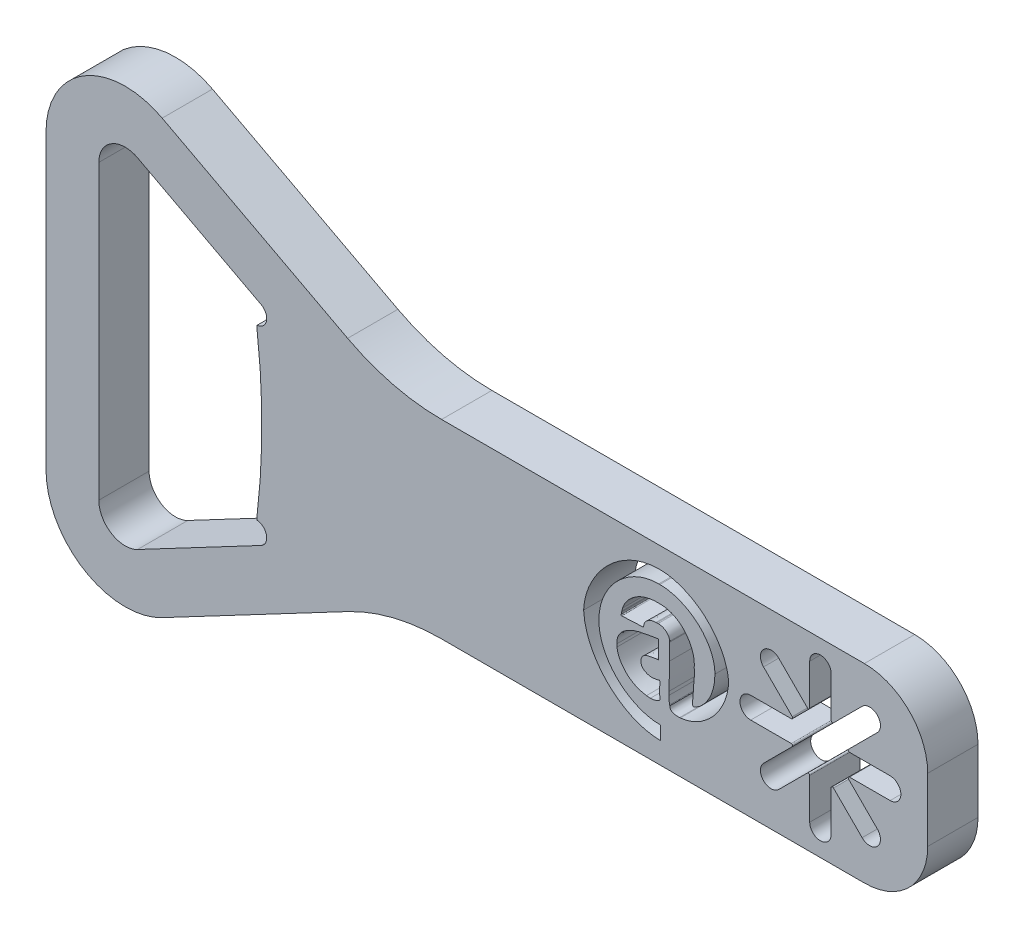
from build123d import *

# Parameters (mm, degrees)
BOSS_EXTRUDE1_DEPTH = 4.7625
CUT_EXTRUDE3_DEPTH  = 5.7625
CUT_EXTRUDE4_DEPTH  = 5.7625
FILLET2_R           = 0.127


with BuildPart() as part:
    # Model → Boss-Extrude1 (new body)
    with BuildSketch(Plane.XY):
        with BuildLine():
            Line((93.450952687, 245.03072761), (75.889188638, 254.308203871))
            ThreePointArc((75.889188638, 254.308203871), (68.514514164, 254.100258783), (64.885909847, 247.676685364))
            Line((64.885909847, 247.676685364), (64.885909847, 219.972883873))
            ThreePointArc((64.885909847, 219.972883873), (68.514514164, 213.549310454), (75.889188638, 213.341365366))
            Line((75.889188638, 213.341365366), (93.450952687, 222.618841627))
            ThreePointArc((93.450952687, 222.618841627), (97.765438869, 224.265076477), (102.349280816, 224.824784618))
            Line((102.349280816, 224.824784618), (142.385909847, 224.824784618))
            ThreePointArc((142.385909847, 224.824784618), (146.628550534, 226.582143931), (148.385909847, 230.824784618))
            Line((148.385909847, 230.824784618), (148.385909847, 236.824784618))
            ThreePointArc((148.385909847, 236.824784618), (146.628550534, 241.067425306), (142.385909847, 242.824784618))
            Line((142.385909847, 242.824784618), (102.349280816, 242.824784618))
            ThreePointArc((102.349280816, 242.824784618), (97.765438869, 243.38449276), (93.450952687, 245.03072761))
        make_face()
        with BuildLine():
            Line((73.553669444, 217.762377704), (85.257358528, 223.945167619))
            ThreePointArc((85.257358528, 223.945167619), (85.71629755, 224.451951724), (85.742353062, 225.135161989))
            ThreePointArc((85.742353062, 225.135161989), (85.41742429, 225.608252807), (84.885909847, 225.824784618))
            Line((84.885909847, 225.824784618), (84.885909847, 226.324784618))
            ThreePointArc((84.885909847, 226.324784618), (85.330378765, 233.824784618), (84.885909847, 241.324784618))
            Line((84.885909847, 241.324784618), (84.885909847, 241.824784618))
            ThreePointArc((84.885909847, 241.824784618), (85.41742429, 242.04131643), (85.742353062, 242.514407247))
            ThreePointArc((85.742353062, 242.514407247), (85.71629755, 243.197617512), (85.257358528, 243.704401618))
            Line((85.257358528, 243.704401618), (73.553669444, 249.887191533))
            ThreePointArc((73.553669444, 249.887191533), (71.095444619, 249.817876503), (69.885909847, 247.676685364))
            Line((69.885909847, 247.676685364), (69.885909847, 219.972883873))
            ThreePointArc((69.885909847, 219.972883873), (71.095444619, 217.831692734), (73.553669444, 217.762377704))
        make_face(mode=Mode.SUBTRACT)
    extrude(amount=BOSS_EXTRUDE1_DEPTH)

    # Sketch4 → Cut-Extrude3 (cut, through all)
    with BuildSketch(Plane.XY.offset(4.7625)):
        with BuildLine():
            Line((137.209909847, 227.223079813), (137.209909847, 231.371943639))
            Line((137.209909847, 231.371943639), (134.276220101, 228.438253894))
            ThreePointArc((134.276220101, 228.438253894), (132.839379122, 228.438253894), (132.839379122, 229.875094873))
            Line((132.839379122, 229.875094873), (135.773068867, 232.808784618))
            Line((135.773068867, 232.808784618), (131.624205042, 232.808784618))
            ThreePointArc((131.624205042, 232.808784618), (130.608205042, 233.824784618), (131.624205042, 234.840784618))
            Line((131.624205042, 234.840784618), (135.773068867, 234.840784618))
            Line((135.773068867, 234.840784618), (132.839379122, 237.774474364))
            ThreePointArc((132.839379122, 237.774474364), (132.839379122, 239.211315343), (134.276220101, 239.211315343))
            Line((134.276220101, 239.211315343), (137.209909847, 236.277625598))
            Line((137.209909847, 236.277625598), (137.209909847, 240.426489423))
            ThreePointArc((137.209909847, 240.426489423), (138.225909847, 241.442489423), (139.241909847, 240.426489423))
            Line((139.241909847, 240.426489423), (139.241909847, 236.277625598))
            Line((139.241909847, 236.277625598), (142.175599592, 239.211315343))
            ThreePointArc((142.175599592, 239.211315343), (143.612440572, 239.211315343), (143.612440572, 237.774474364))
            Line((143.612440572, 237.774474364), (140.678750826, 234.840784618))
            Line((140.678750826, 234.840784618), (144.827614652, 234.840784618))
            ThreePointArc((144.827614652, 234.840784618), (145.843614652, 233.824784618), (144.827614652, 232.808784618))
            Line((144.827614652, 232.808784618), (140.678750826, 232.808784618))
            Line((140.678750826, 232.808784618), (143.612440572, 229.875094873))
            ThreePointArc((143.612440572, 229.875094873), (143.612440572, 228.438253894), (142.175599592, 228.438253894))
            Line((142.175599592, 228.438253894), (139.241909847, 231.371943639))
            Line((139.241909847, 231.371943639), (139.241909847, 227.223079813))
            ThreePointArc((139.241909847, 227.223079813), (138.225909847, 226.207079813), (137.209909847, 227.223079813))
        make_face()
    extrude(amount=-CUT_EXTRUDE3_DEPTH, mode=Mode.SUBTRACT)

    # Sketch5 → Cut-Extrude4 (cut, through all)
    with BuildSketch(Plane.XY.offset(4.7625)):
        with BuildLine():
            add(Edge.make_bspline(
                [(126.288361494, 234.030612945), (126.288361494, 234.062228992), (126.288361494, 234.126390968), (126.288361494, 234.190552945), (126.288361494, 234.223098875)],
                knots=[0, 0, 0, 0, 9.4848e-05, 0.000192486, 0.000192486, 0.000192486, 0.000192486], degree=3))
            add(Edge.make_bspline(
                [(126.288361494, 234.223098875), (126.287357171, 234.260374858), (126.285441418, 234.331478997), (126.274187869, 234.401702957), (126.268833936, 234.435112363)],
                knots=[0, 0, 0, 0, 0.000111725, 0.000213117, 0.000213117, 0.000213117, 0.000213117], degree=3))
            add(Edge.make_bspline(
                [(126.268833936, 234.435112363), (126.269705178, 234.449063035), (126.271683634, 234.480742831), (126.276195212, 234.530214354), (126.28660925, 234.579851384), (126.287813896, 234.61267678), (126.288361494, 234.627598294)],
                knots=[0, 0, 0, 0, 4.1938e-05, 9.5234e-05, 0.000148894, 0.000193615, 0.000193615, 0.000193615, 0.000193615], degree=3))
            add(Edge.make_bspline(
                [(126.288361494, 234.627598294), (126.284874052, 234.739324272), (126.277954936, 234.960989623), (126.230695985, 235.289801797), (126.144832923, 235.609536287), (126.030758138, 235.919931115), (125.89184278, 236.219239832), (125.726670115, 236.500079901), (125.541759748, 236.764765282), (125.334862846, 237.009659426), (125.10970704, 237.237606073), (124.859990194, 237.438308088), (124.591026849, 237.615132637), (124.303890841, 237.764741345), (124.004254122, 237.8891917), (123.692053743, 237.974520596), (123.373339224, 238.030548458), (123.157678136, 238.036405686), (123.049576497, 238.039341662)],
                knots=[0, 0, 0, 0, 0.000335176, 0.000664993, 0.000993841, 0.001326558, 0.001656033, 0.001982338, 0.002302748, 0.002623497, 0.002943055, 0.003262406, 0.003582731, 0.003907159, 0.004232485, 0.004553986, 0.004876393, 0.005200425, 0.005200425, 0.005200425, 0.005200425], degree=3))
            Line((123.049576497, 238.039341662), (122.759452777, 238.039341662))
            Line((122.759452777, 238.039341662), (122.739925218, 238.039341662))
            Line((122.739925218, 238.039341662), (122.700870102, 238.039341662))
            add(Edge.make_bspline(
                [(122.700870102, 238.039341662), (122.532890784, 238.032310589), (122.193481031, 238.018103989), (121.694072094, 237.903577601), (121.209266645, 237.733330729), (120.756781994, 237.492891404), (120.344031914, 237.188375917), (120.042891277, 236.883831305), (119.829268268, 236.614302308), (119.693745608, 236.394972755), (119.573326683, 236.164672688), (119.512463554, 236.001776947), (119.481612663, 235.919206781)],
                knots=[0, 0, 0, 0, 0.000503445, 0.001017233, 0.0015299, 0.002041555, 0.002548167, 0.003063015, 0.003321385, 0.003578351, 0.003835363, 0.004099556, 0.004099556, 0.004099556, 0.004099556], degree=3))
            add(Edge.make_bspline(
                [(119.481612663, 235.919206781), (119.476029997, 235.895032488), (119.465522894, 235.849534197), (119.450389171, 235.783736573), (119.439961658, 235.717000075), (119.428996042, 235.672708367), (119.423029989, 235.648610618)],
                knots=[0, 0, 0, 0, 7.4437e-05, 0.000140098, 0.000202476, 0.000276913, 0.000276913, 0.000276913, 0.000276913], degree=3))
            add(Edge.make_bspline(
                [(119.423029989, 235.648610618), (119.417749333, 235.631067462), (119.408401324, 235.600011927), (119.404987708, 235.567784676), (119.403502431, 235.553762479)],
                knots=[0, 0, 0, 0, 5.4808e-05, 9.7023e-05, 9.7023e-05, 9.7023e-05, 9.7023e-05], degree=3))
            add(Edge.make_bspline(
                [(119.403502431, 235.553762479), (119.399331446, 235.529463416), (119.386890201, 235.456983986), (119.361678872, 235.387763194), (119.344919757, 235.34174899)],
                knots=[0, 0, 0, 0, 7.386e-05, 0.00022031, 0.00022031, 0.00022031, 0.00022031], degree=3))
            add(Edge.make_bspline(
                [(119.344919757, 235.34174899), (119.337968424, 235.328463107), (119.326264529, 235.306093789), (119.326214095, 235.266353615), (119.360790812, 235.243804404), (119.387482155, 235.243996127), (119.403502431, 235.2441112)],
                knots=[0, 0, 0, 0, 4.5068e-05, 7.5881e-05, 0.000107688, 0.000155439, 0.000155439, 0.000155439, 0.000155439], degree=3))
            add(Edge.make_bspline(
                [(119.403502431, 235.2441112), (119.570844616, 235.25586831), (119.904440478, 235.279306054), (120.405794106, 235.303774184), (120.907134076, 235.321959023), (121.241885769, 235.335152335), (121.409261615, 235.34174899)],
                knots=[0, 0, 0, 0, 0.000503252, 0.00100323, 0.001505747, 0.002008264, 0.002008264, 0.002008264, 0.002008264], degree=3))
            add(Edge.make_bspline(
                [(121.409261615, 235.34174899), (121.431913124, 235.342566401), (121.47193382, 235.344010603), (121.482699491, 235.381340603), (121.487371848, 235.397542014)],
                knots=[0, 0, 0, 0, 6.022e-05, 0.000106397, 0.000106397, 0.000106397, 0.000106397], degree=3))
            add(Edge.make_bspline(
                [(121.487371848, 235.397542014), (121.491201998, 235.46513789), (121.498714198, 235.59771593), (121.571888813, 235.783987972), (121.691816601, 235.945189734), (121.850920335, 236.079600892), (122.035966179, 236.183261067), (122.228917359, 236.268810695), (122.433939123, 236.312588896), (122.572378602, 236.319975918), (122.642287428, 236.323706199)],
                knots=[0, 0, 0, 0, 0.000202091, 0.000396368, 0.000589982, 0.000799671, 0.001015936, 0.001224732, 0.001430486, 0.001640378, 0.001640378, 0.001640378, 0.001640378], degree=3))
            Line((122.642287428, 236.323706199), (122.72039766, 236.323706199))
            add(Edge.make_bspline(
                [(122.72039766, 236.323706199), (122.737952884, 236.329039699), (122.781482242, 236.34226447), (122.827087866, 236.342871525), (122.854300916, 236.343233757)],
                knots=[0, 0, 0, 0, 5.4808e-05, 0.0001359, 0.0001359, 0.0001359, 0.0001359], degree=3))
            add(Edge.make_bspline(
                [(122.854300916, 236.343233757), (122.920544034, 236.339687282), (123.052853891, 236.332603775), (123.247737126, 236.285389875), (123.430676504, 236.198059761), (123.601516399, 236.086454092), (123.749124755, 235.949946057), (123.86024378, 235.790137501), (123.923147061, 235.608388815), (123.932112793, 235.481689657), (123.936685566, 235.417069572)],
                knots=[0, 0, 0, 0, 0.000198771, 0.000397013, 0.000596722, 0.000804078, 0.00100734, 0.001196131, 0.001382287, 0.001576062, 0.001576062, 0.001576062, 0.001576062], degree=3))
            Line((123.936685566, 235.417069572), (123.936685566, 235.34174899))
            add(Edge.make_bspline(
                [(123.936685566, 235.34174899), (123.937375637, 235.21342241), (123.938745833, 234.9586187), (123.945025157, 234.578314027), (123.951388449, 234.19801061), (123.952740199, 233.944136484), (123.953423473, 233.815809806)],
                knots=[0, 0, 0, 0, 0.000384982, 0.000764416, 0.00114106, 0.001526042, 0.001526042, 0.001526042, 0.001526042], degree=3))
            add(Edge.make_bspline(
                [(123.953423473, 233.815809806), (123.952176459, 233.603787581), (123.949682178, 233.179700314), (123.934949795, 232.545483984), (123.914327483, 231.915763642), (123.890127163, 231.49849923), (123.878102892, 231.291175506)],
                knots=[0, 0, 0, 0, 0.000636065, 0.001272258, 0.001903114, 0.002526107, 0.002526107, 0.002526107, 0.002526107], degree=3))
            Line((123.878102892, 231.291175506), (123.878102892, 230.961996669))
            add(Edge.make_bspline(
                [(123.878102892, 230.961996669), (123.880605234, 230.841877602), (123.885838923, 230.590646624), (123.919249383, 230.341568757), (123.936685566, 230.211580507)],
                knots=[0, 0, 0, 0, 0.000360135, 0.000753229, 0.000753229, 0.000753229, 0.000753229], degree=3))
            add(Edge.make_bspline(
                [(123.936685566, 230.211580507), (123.936288816, 230.194298861), (123.935619578, 230.165148131), (123.962149175, 230.156513522), (123.972951031, 230.152997833)],
                knots=[0, 0, 0, 0, 4.5412e-05, 7.6601e-05, 7.6601e-05, 7.6601e-05, 7.6601e-05], degree=3))
            add(Edge.make_bspline(
                [(123.972951031, 230.152997833), (123.969677746, 230.115701273), (123.963347915, 230.043577734), (123.993538681, 229.936202659), (124.058453636, 229.843647926), (124.150714237, 229.758963596), (124.282319592, 229.694553439), (124.453269392, 229.655081686), (124.663707985, 229.640900003), (124.816376129, 229.647359743), (124.899115216, 229.650860624)],
                knots=[0, 0, 0, 0, 0.000111621, 0.000215851, 0.000326491, 0.000446964, 0.000587945, 0.000760476, 0.000970368, 0.00121871, 0.00121871, 0.00121871, 0.00121871], degree=3))
            Line((124.899115216, 229.650860624), (124.957697891, 229.650860624))
            add(Edge.make_bspline(
                [(124.957697891, 229.650860624), (125.116423689, 229.672499935), (125.430835481, 229.715364135), (125.890707604, 229.840792108), (126.331759051, 230.017097808), (126.753829843, 230.242168248), (127.154421239, 230.506951649), (127.529346965, 230.806069197), (127.88230805, 231.13039973), (128.20213999, 231.489044016), (128.493855381, 231.8725217), (128.756173255, 232.279139433), (128.98024074, 232.710124345), (129.176625101, 233.157275459), (129.332079182, 233.617400488), (129.444026579, 234.08222801), (129.514124613, 234.547350917), (129.522819173, 234.857972518), (129.527146491, 235.012570154)],
                knots=[0, 0, 0, 0, 0.000480185, 0.000951173, 0.001425685, 0.001902389, 0.002383642, 0.002864191, 0.003339915, 0.003819937, 0.004303675, 0.004784224, 0.005269631, 0.00575938, 0.006248102, 0.006724439, 0.007192336, 0.007655955, 0.007655955, 0.007655955, 0.007655955], degree=3))
            add(Edge.make_bspline(
                [(129.527146491, 235.012570154), (129.499968921, 235.209643523), (129.445645037, 235.603563621), (129.284504493, 236.17831865), (129.07281248, 236.737839285), (128.800748353, 237.274053858), (128.48292554, 237.786371961), (128.125242918, 238.269359083), (127.730841294, 238.722236362), (127.294843443, 239.135294209), (126.829529381, 239.516653016), (126.332460459, 239.853867247), (125.807778921, 240.14834831), (125.259963177, 240.398005444), (124.697439734, 240.602781207), (124.125634557, 240.747874265), (123.549990434, 240.838682046), (123.164279976, 240.848961208), (122.971466265, 240.854099683)],
                knots=[0, 0, 0, 0, 0.000596209, 0.001191733, 0.001785981, 0.002388558, 0.002992387, 0.003592733, 0.004189758, 0.004791553, 0.005392365, 0.005992789, 0.006591063, 0.007195259, 0.007797062, 0.008384348, 0.008962728, 0.009540859, 0.009540859, 0.009540859, 0.009540859], degree=3))
            add(Edge.make_bspline(
                [(122.971466265, 240.854099683), (122.747880933, 240.84695311), (122.301930823, 240.832698977), (121.638624117, 240.722552779), (120.987043716, 240.543869541), (120.35174798, 240.294083945), (119.740846647, 239.985425796), (119.160535055, 239.623547568), (118.613568285, 239.211893159), (118.105051802, 238.74936039), (117.636983363, 238.244300848), (117.2109184, 237.703047078), (116.827962859, 237.128243222), (116.493941349, 236.521241708), (116.213480047, 235.891805043), (116.004959522, 235.243489805), (115.856538683, 234.584256127), (115.818386295, 234.137339142), (115.799273132, 233.913447597)],
                knots=[0, 0, 0, 0, 0.000670498, 0.001337335, 0.002011398, 0.002694179, 0.003381595, 0.004062007, 0.004743242, 0.005432489, 0.006121397, 0.006806726, 0.007496876, 0.008191068, 0.008883042, 0.009560565, 0.010231394, 0.010904827, 0.010904827, 0.010904827, 0.010904827], degree=3))
            add(Edge.make_bspline(
                [(115.799273132, 233.913447597), (115.818437762, 233.686783971), (115.85676654, 233.233462412), (116.004941877, 232.564025516), (116.212950591, 231.905339791), (116.493573701, 231.266084612), (116.830171305, 230.651841402), (117.216662949, 230.070336392), (117.64663574, 229.523573914), (118.124911445, 229.01884636), (118.641974186, 228.556993499), (119.195780518, 228.141433186), (119.781883242, 227.772254872), (120.400230667, 227.454829906), (121.041156048, 227.193533337), (121.700880033, 227.007514943), (122.37092872, 226.884524976), (122.823092769, 226.865273169), (123.049576497, 226.855630162)],
                knots=[0, 0, 0, 0, 0.000681754, 0.001363492, 0.002051637, 0.002751278, 0.003454148, 0.004150489, 0.004843654, 0.005538283, 0.006233752, 0.006921122, 0.007613068, 0.008309252, 0.009003926, 0.009685617, 0.01036256, 0.011041914, 0.011041914, 0.011041914, 0.011041914], degree=3))
            add(Edge.make_bspline(
                [(123.049576497, 226.855630162), (123.052148079, 226.845015714), (123.056229746, 226.828168248), (123.070031638, 226.862323268), (123.063980065, 226.902709315), (123.065419402, 226.945923951), (123.066314404, 226.97279551)],
                knots=[0, 0, 0, 0, 2.1245e-05, 3.3721e-05, 8.1227e-05, 0.000159337, 0.000159337, 0.000159337, 0.000159337], degree=3))
            add(Edge.make_bspline(
                [(123.066314404, 226.97279551), (123.066314404, 227.038817255), (123.066314404, 227.186668766), (123.066314404, 227.334520277), (123.066314404, 227.416350045)],
                knots=[0, 0, 0, 0, 0.000198065, 0.000443555, 0.000443555, 0.000443555, 0.000443555], degree=3))
            add(Edge.make_bspline(
                [(123.066314404, 227.416350045), (123.067024793, 227.498218566), (123.068413429, 227.658251413), (123.073136568, 227.851288054), (123.077595488, 227.98791512), (123.088879763, 228.05918767), (123.090822037, 228.105889567), (123.102333605, 228.123157155), (123.10536952, 228.127711091)],
                knots=[0, 0, 0, 0, 0.000245505, 0.000479902, 0.000580485, 0.000653497, 0.000698909, 0.000715175, 0.000715175, 0.000715175, 0.000715175], degree=3))
            add(Edge.make_bspline(
                [(123.10536952, 228.127711091), (122.917131676, 228.13246314), (122.541299056, 228.141951005), (121.985064615, 228.237691379), (121.435903156, 228.377319702), (120.904375071, 228.583352494), (120.391507237, 228.832819659), (119.908655023, 229.127669352), (119.453114929, 229.457354461), (119.032279307, 229.828632894), (118.647603459, 230.236444232), (118.299476347, 230.675003476), (117.995797898, 231.147678872), (117.726737508, 231.643138666), (117.511105666, 232.164240447), (117.357449374, 232.703213472), (117.261799967, 233.255402219), (117.250156669, 233.628524744), (117.244312433, 233.815809806)],
                knots=[0, 0, 0, 0, 0.0005642, 0.001126472, 0.001688751, 0.002261771, 0.00283318, 0.003397724, 0.003956825, 0.004518162, 0.005078598, 0.005636702, 0.006195364, 0.006761993, 0.007326151, 0.007883307, 0.008440525, 0.009002084, 0.009002084, 0.009002084, 0.009002084], degree=3))
            add(Edge.make_bspline(
                [(117.244312433, 233.815809806), (117.249259227, 234.001234432), (117.259108066, 234.370406386), (117.351519444, 234.917475273), (117.488536025, 235.456025126), (117.689158831, 235.979843046), (117.936130486, 236.484109233), (118.224824042, 236.964384878), (118.554669616, 237.415038498), (118.926437426, 237.833387694), (119.333256467, 238.21693451), (119.769624915, 238.566600417), (120.241289715, 238.869962515), (120.738162762, 239.135464985), (121.259689654, 239.351449233), (121.798133632, 239.50792578), (122.351530935, 239.60382758), (122.724667991, 239.615291372), (122.91288359, 239.62107387)],
                knots=[0, 0, 0, 0, 0.000555841, 0.001106654, 0.001660131, 0.00222074, 0.002785911, 0.003342794, 0.003899642, 0.004458889, 0.005019324, 0.005575243, 0.006133905, 0.00669922, 0.007263379, 0.007823987, 0.008378455, 0.008942799, 0.008942799, 0.008942799, 0.008942799], degree=3))
            Line((122.91288359, 239.62107387), (123.010521381, 239.62107387))
            add(Edge.make_bspline(
                [(123.010521381, 239.62107387), (123.170728722, 239.61706101), (123.490810735, 239.609043623), (123.966982208, 239.535342103), (124.438956443, 239.421498157), (124.902152828, 239.259011667), (125.351516634, 239.058003435), (125.783907831, 238.827839925), (126.189397552, 238.557522868), (126.571164611, 238.256561045), (126.927049794, 237.926918151), (127.242162074, 237.560482336), (127.526242553, 237.1702733), (127.767513683, 236.750808871), (127.972281017, 236.31148265), (128.114935234, 235.848561074), (128.212167161, 235.369861987), (128.227684244, 235.04373276), (128.235538004, 234.878666898)],
                knots=[0, 0, 0, 0, 0.000480339, 0.00095968, 0.001442096, 0.001935265, 0.002429813, 0.002917842, 0.003402961, 0.003889617, 0.004375129, 0.004855638, 0.005337214, 0.005820951, 0.006305323, 0.006787933, 0.007271026, 0.007766124, 0.007766124, 0.007766124, 0.007766124], degree=3))
            add(Edge.make_bspline(
                [(128.235538004, 234.878666898), (128.229386832, 234.695117759), (128.216757345, 234.31825765), (128.119408487, 233.753726914), (127.96255658, 233.19378156), (127.764349438, 232.75223033), (127.575059882, 232.41845959), (127.411901797, 232.182651119), (127.236249197, 231.954312701), (127.042886615, 231.741983121), (126.834400284, 231.545908702), (126.603309665, 231.383461256), (126.360408961, 231.238580657), (126.184466838, 231.171514291), (126.095875564, 231.137744692)],
                knots=[0, 0, 0, 0, 0.000550417, 0.001130108, 0.001713705, 0.002290678, 0.002576831, 0.002863894, 0.003150157, 0.003440455, 0.003724753, 0.004006563, 0.004286489, 0.00457039, 0.00457039, 0.00457039, 0.00457039], degree=3))
            add(Edge.make_bspline(
                [(126.095875564, 231.137744692), (126.097895957, 231.246567215), (126.10193969, 231.464371031), (126.121950876, 231.791894273), (126.153582044, 232.11998798), (126.178336112, 232.339187497), (126.190723703, 232.448880738)],
                knots=[0, 0, 0, 0, 0.000326496, 0.000653469, 0.000984075, 0.001315246, 0.001315246, 0.001315246, 0.001315246], degree=3))
            Line((126.190723703, 232.448880738), (126.22977882, 233.065393644))
            add(Edge.make_bspline(
                [(126.22977882, 233.065393644), (126.247214569, 233.226108453), (126.282019222, 233.54692193), (126.286250112, 233.869589174), (126.288361494, 234.030612945)],
                knots=[0, 0, 0, 0, 0.000484669, 0.00096748, 0.00096748, 0.00096748, 0.00096748], degree=3))
        make_face()
        with BuildLine():
            add(Edge.make_bspline(
                [(123.049576497, 230.192052949), (123.032138415, 230.306208789), (122.997955532, 230.529981995), (122.993282803, 230.756289644), (122.990993823, 230.86714853)],
                knots=[0, 0, 0, 0, 0.000346018, 0.000678279, 0.000678279, 0.000678279, 0.000678279], degree=3))
            add(Edge.make_bspline(
                [(122.990993823, 230.86714853), (122.990993823, 230.904343879), (122.990993823, 230.975015041), (122.990993823, 231.045686204), (122.990993823, 231.079162018)],
                knots=[0, 0, 0, 0, 0.000111586, 0.000212013, 0.000212013, 0.000212013, 0.000212013], degree=3))
            add(Edge.make_bspline(
                [(122.990993823, 231.079162018), (122.991998146, 231.116438001), (122.993913899, 231.18754214), (123.005167448, 231.2577661), (123.010521381, 231.291175506)],
                knots=[0, 0, 0, 0, 0.000111725, 0.000213117, 0.000213117, 0.000213117, 0.000213117], degree=3))
            Line((123.010521381, 231.291175506), (123.010521381, 231.715202482))
            add(Edge.make_bspline(
                [(123.010521381, 231.715202482), (123.00923885, 231.726274923), (123.006870918, 231.74671792), (122.995204963, 231.776794914), (122.958253816, 231.783945837), (122.942294997, 231.765612233), (122.932411148, 231.754257599)],
                knots=[0, 0, 0, 0, 3.3938e-05, 6.2659e-05, 8.8378e-05, 0.000130223, 0.000130223, 0.000130223, 0.000130223], degree=3))
            add(Edge.make_bspline(
                [(122.932411148, 231.754257599), (122.897625013, 231.736911213), (122.821689546, 231.699045382), (122.688606441, 231.673832473), (122.543749365, 231.656885597), (122.444226925, 231.643730325), (122.394008475, 231.63709225)],
                knots=[0, 0, 0, 0, 0.000116131, 0.000253506, 0.000402641, 0.000554543, 0.000554543, 0.000554543, 0.000554543], degree=3))
            add(Edge.make_bspline(
                [(122.394008475, 231.63709225), (122.380046102, 231.636318425), (122.350185865, 231.634663507), (122.305640607, 231.628963357), (122.261177823, 231.622590402), (122.232228282, 231.621082088), (122.218260451, 231.620354343)],
                knots=[0, 0, 0, 0, 4.1938e-05, 8.9689e-05, 0.000134671, 0.000176608, 0.000176608, 0.000176608, 0.000176608], degree=3))
            add(Edge.make_bspline(
                [(122.218260451, 231.620354343), (122.10827359, 231.6358787), (121.87877877, 231.668271291), (121.609536817, 231.790121479), (121.419072289, 231.92966245), (121.31065073, 232.061743164), (121.245582214, 232.219308005), (121.23946523, 232.33202994), (121.236303243, 232.390298063)],
                knots=[0, 0, 0, 0, 0.000332109, 0.000692968, 0.000872071, 0.001036755, 0.001199418, 0.001373475, 0.001373475, 0.001373475, 0.001373475], degree=3))
            Line((121.236303243, 232.390298063), (121.236303243, 232.468408296))
            add(Edge.make_bspline(
                [(121.236303243, 232.468408296), (121.237746224, 232.51131596), (121.240503171, 232.59329497), (121.265758745, 232.709473442), (121.308250985, 232.812545724), (121.38771571, 232.933183135), (121.52710811, 233.055280018), (121.729824115, 233.160058235), (121.957230819, 233.232389653), (122.198702382, 233.279283964), (122.441622958, 233.315249626), (122.602341302, 233.342246854), (122.681342544, 233.355517365)],
                knots=[0, 0, 0, 0, 0.000128597, 0.000245695, 0.000354492, 0.000461267, 0.000676504, 0.000901153, 0.001141986, 0.001389826, 0.001638402, 0.001878717, 0.001878717, 0.001878717, 0.001878717], degree=3))
            add(Edge.make_bspline(
                [(122.681342544, 233.355517365), (122.72051223, 233.356203733), (122.785108446, 233.35733565), (122.848769891, 233.36804129), (122.873828474, 233.372255271)],
                knots=[0, 0, 0, 0, 0.000117298, 0.000193441, 0.000193441, 0.000193441, 0.000193441], degree=3))
            Line((122.873828474, 233.372255271), (122.91288359, 233.430837946))
            Line((122.91288359, 233.430837946), (122.91288359, 235.032097712))
            add(Edge.make_bspline(
                [(122.91288359, 235.032097712), (122.910791352, 235.049533031), (122.906606875, 235.084403671), (122.871736236, 235.088588148), (122.854300916, 235.090680386)],
                knots=[0, 0, 0, 0, 4.6763e-05, 9.3526e-05, 9.3526e-05, 9.3526e-05, 9.3526e-05], degree=3))
            Line((122.854300916, 235.090680386), (122.547439288, 235.032097712))
            add(Edge.make_bspline(
                [(122.547439288, 235.032097712), (122.5325184, 235.031543696), (122.499694382, 235.030324932), (122.450953312, 235.020220975), (122.401539413, 235.015133015), (122.369838419, 235.013389033), (122.354953358, 235.012570154)],
                knots=[0, 0, 0, 0, 4.4722e-05, 9.8382e-05, 0.000148904, 0.000193626, 0.000193626, 0.000193626, 0.000193626], degree=3))
            add(Edge.make_bspline(
                [(122.354953358, 235.012570154), (122.179049026, 234.98366063), (121.810400903, 234.923074052), (121.249247775, 234.813252906), (120.679817639, 234.671172294), (120.230610569, 234.485430802), (119.89968534, 234.304448151), (119.674885813, 234.145478208), (119.467019822, 233.970492167), (119.282055979, 233.773493259), (119.127258278, 233.551193914), (119.017027136, 233.297633109), (118.9530092, 233.015541866), (118.944703926, 232.818377937), (118.940420338, 232.716687249)],
                knots=[0, 0, 0, 0, 0.000534748, 0.001120687, 0.001715485, 0.002292087, 0.002573067, 0.002845483, 0.003116597, 0.00338702, 0.003653968, 0.003925038, 0.004211287, 0.004516177, 0.004516177, 0.004516177, 0.004516177], degree=3))
            add(Edge.make_bspline(
                [(118.940420338, 232.716687249), (118.941092857, 232.693429654), (118.942305643, 232.651488125), (118.947616802, 232.591812286), (118.959827668, 232.533027329), (118.959904474, 232.491746572), (118.959947897, 232.468408296)],
                knots=[0, 0, 0, 0, 6.9797e-05, 0.000125868, 0.000179528, 0.000249325, 0.000249325, 0.000249325, 0.000249325], degree=3))
            add(Edge.make_bspline(
                [(118.959947897, 232.468408296), (118.971983309, 232.382484184), (118.995795805, 232.212480243), (119.06495139, 231.965004681), (119.156315156, 231.727075147), (119.314263269, 231.425949014), (119.55997545, 231.078212008), (119.846586739, 230.762748405), (120.107250896, 230.543224254), (120.31683746, 230.395792775), (120.538379941, 230.263324181), (120.849124323, 230.112969455), (121.253067433, 229.966005502), (121.589410057, 229.910002873), (121.755178359, 229.88240167)],
                knots=[0, 0, 0, 0, 0.000260037, 0.000514492, 0.000768856, 0.001023387, 0.001532573, 0.002041881, 0.002297268, 0.002553461, 0.002809896, 0.00307065, 0.003588572, 0.004091901, 0.004091901, 0.004091901, 0.004091901], degree=3))
            add(Edge.make_bspline(
                [(121.755178359, 229.88240167), (121.786829007, 229.878027961), (121.848309116, 229.869532208), (121.938738804, 229.852336015), (122.03041028, 229.848666662), (122.091806975, 229.846996143), (122.123412312, 229.846136205)],
                knots=[0, 0, 0, 0, 9.5868e-05, 0.00018622, 0.000275663, 0.000370552, 0.000370552, 0.000370552, 0.000370552], degree=3))
            add(Edge.make_bspline(
                [(122.123412312, 229.846136205), (122.207508032, 229.848560595), (122.371201795, 229.853279711), (122.604991762, 229.912919324), (122.822420829, 229.999987114), (122.947842738, 230.088991174), (123.010521381, 230.133470275)],
                knots=[0, 0, 0, 0, 0.000251626, 0.000489794, 0.000719835, 0.000949638, 0.000949638, 0.000949638, 0.000949638], degree=3))
            add(Edge.make_bspline(
                [(123.010521381, 230.133470275), (123.022469191, 230.143617361), (123.041379845, 230.159677881), (123.047370688, 230.183340461), (123.049576497, 230.192052949)],
                knots=[0, 0, 0, 0, 4.5412e-05, 7.1877e-05, 7.1877e-05, 7.1877e-05, 7.1877e-05], degree=3))
        make_face()
    extrude(amount=-CUT_EXTRUDE4_DEPTH, mode=Mode.SUBTRACT)

    # Fillet2
    fillet2_edges = [part.edges().sort_by_distance(p)[0] for p in [
        (139.241909847, 236.277625598, 2.38125),
        (140.678750826, 234.840784618, 2.38125),
        (139.241909847, 231.371943639, 2.38125),
        (140.678750826, 232.808784618, 2.38125),
        (137.209909847, 231.371943639, 2.38125),
        (135.773068867, 232.808784618, 2.38125),
        (135.773068867, 234.840784618, 2.38125),
        (137.209909847, 236.277625598, 2.38125),
        (126.095875564, 231.137744692, 2.38125),
    ]]
    fillet(fillet2_edges, radius=FILLET2_R)


solid = part.part
